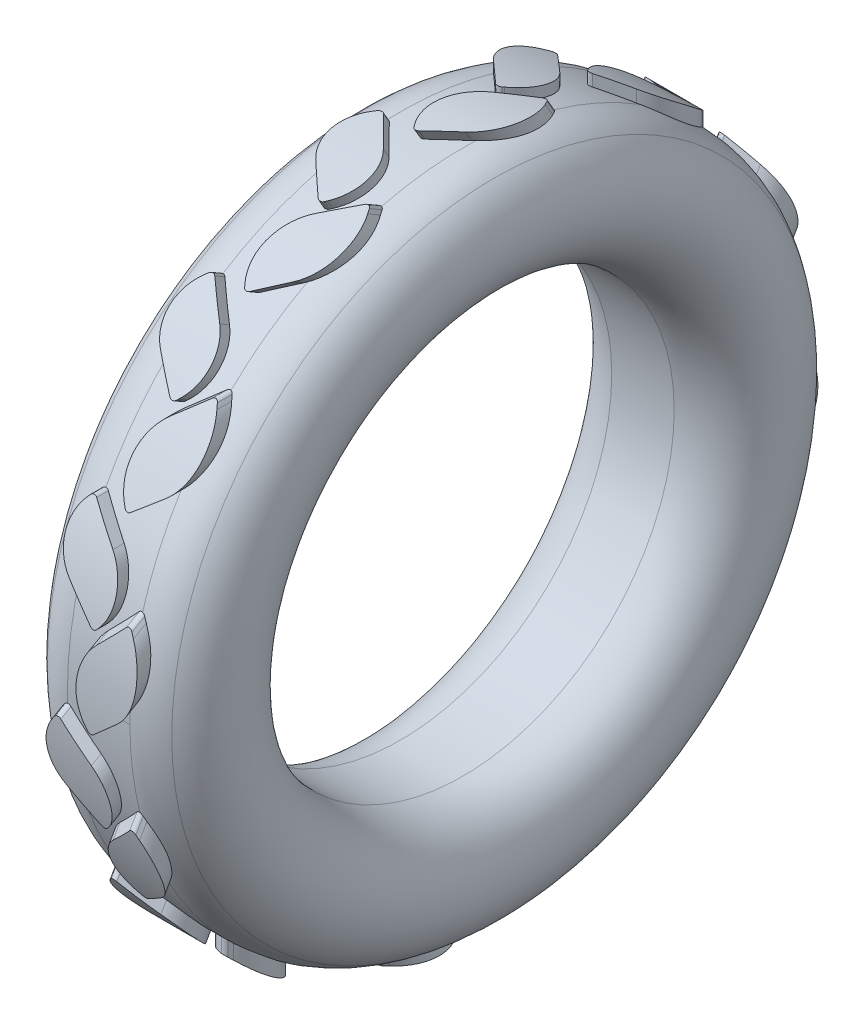
from build123d import *

# Parameters (mm, degrees)
BOSS_EXTRUDE2_REACH = 183.851
CUT_EXTRUDE1_DEPTH  = 117.403984849
CIRPATTERN2_COUNT   = 12


with BuildPart() as part:
    # Sketch1 → Revolve2 (revolve)
    with BuildSketch(Plane.XY, mode=Mode.PRIVATE) as revolve2_sk:
        with BuildLine():
            Line((-7.5, 80), (7.5, 80))
            ThreePointArc((7.5, 80), (11.445221398, 79.332926724), (14.951817501, 77.405871354))
            ThreePointArc((14.951817501, 77.405871354), (20.08259217, 61.607964749), (7.5, 50.764668382))
            Line((7.5, 50.764668382), (-7.5, 50.764668382))
            ThreePointArc((-7.5, 50.764668382), (-20.08259217, 61.607964749), (-14.951817501, 77.405871354))
            ThreePointArc((-14.951817501, 77.405871354), (-11.445221398, 79.332926724), (-7.5, 80))
        make_face()
    revolve(revolve2_sk.sketch.rotate(Axis((0, 0, 0), (1, 0, 0)), 90), axis=Axis((0, 0, 0), (1, 0, 0)))

    # Sketch3 → Boss-Extrude2 (add, up to next)
    with BuildSketch(Plane(origin=(0, 82, 0), x_dir=(1, 0, 0), z_dir=(0, 1, 0)), mode=Mode.PRIVATE) as boss_extrude2_sk1:
        with BuildLine():
            Line((-1.101256595, 16.463545507), (-7.765089072, 22.606945227))
            ThreePointArc((-7.765089072, 22.606945227), (-10.973435179, 29.439481126), (-8.491780794, 36.568185291))
            Line((-8.491780794, 36.568185291), (-8.176119623, 36.926638579))
            ThreePointArc((-8.176119623, 36.926638579), (-7.477617242, 37.264396564), (-6.747823451, 37.000982334))
            Line((-6.747823451, 37.000982334), (-0.083990974, 30.857582614))
            ThreePointArc((-0.083990974, 30.857582614), (3.124355134, 24.025046715), (0.642700748, 16.89634255))
            Line((0.642700748, 16.89634255), (0.327039578, 16.537889262))
            ThreePointArc((0.327039578, 16.537889262), (-0.371462804, 16.200131277), (-1.101256595, 16.463545507))
        make_face()
    boss_extrude2_tool1 = extrude(boss_extrude2_sk1.sketch, amount=-BOSS_EXTRUDE2_REACH, mode=Mode.PRIVATE) - part.part
    # Sketch3 → Boss-Extrude2 (add, up to next)
    with BuildSketch(Plane(origin=(0, 82, 0), x_dir=(1, 0, 0), z_dir=(0, 1, 0)), mode=Mode.PRIVATE) as boss_extrude2_sk2:
        with BuildLine():
            Line((1.084752357, 37.609371056), (6.991157215, 42.191838317))
            ThreePointArc((6.991157215, 42.191838317), (10.787185022, 48.877835615), (8.715761537, 56.281996049))
            Line((8.715761537, 56.281996049), (8.11427934, 57.045310452))
            ThreePointArc((8.11427934, 57.045310452), (7.450320314, 57.418978065), (6.715839438, 57.216476421))
            Line((6.715839438, 57.216476421), (0.80943458, 52.63400916))
            ThreePointArc((0.80943458, 52.63400916), (-2.986593227, 45.948011861), (-0.915169742, 38.543851427))
            Line((-0.915169742, 38.543851427), (-0.313687545, 37.780537025))
            ThreePointArc((-0.313687545, 37.780537025), (0.350271481, 37.406869411), (1.084752357, 37.609371056))
        make_face()
    boss_extrude2_tool2 = extrude(boss_extrude2_sk2.sketch, amount=-BOSS_EXTRUDE2_REACH, mode=Mode.PRIVATE) - part.part
    boss_extrude2_1 = boss_extrude2_tool1.solids().sort_by_distance((-3.92454, 82, -26.732264))[0]
    add(boss_extrude2_1)
    boss_extrude2_2 = boss_extrude2_tool2.solids().sort_by_distance((3.900296, 82, -47.412924))[0]
    add(boss_extrude2_2)
    boss_extrude2 = boss_extrude2_1 + boss_extrude2_2  # Boss-Extrude2 as one shape, for the pattern or mirror that repeats it

    # Sketch4 → Cut-Extrude1 (cut, symmetric)
    with BuildSketch(Plane(origin=(0, 0, 0), x_dir=(0, 0, -1), z_dir=(1, 0, 0))):
        with BuildLine():
            Line((16.198779388, 82), (16.198779388, 80.894063728))
            ThreePointArc((16.198779388, 80.894063728), (38.372838025, 73.032700223), (57.42638555, 59.232256775))
            Line((57.42638555, 59.232256775), (57.42638555, 82))
            add(Edge.make_bspline(
                [(16.198779388, 82), (15.488555572, 83.729394535), (19.769359109, 84.523606768), (32.707694781, 86.891237657), (47.667286982, 94.196998332), (57.42638555, 82)],
                knots=[0, 0, 0, 0, 0.106935157, 0.195115191, 1, 1, 1, 1], degree=3))
        make_face()
    cut_extrude1 = extrude(amount=CUT_EXTRUDE1_DEPTH, both=True, mode=Mode.SUBTRACT)

    # CirPattern2: Boss-Extrude2, Cut-Extrude1 ×12 about axis
    cirpattern2_axis = Axis((0, 0, 0), (1, 0, 0))
    add([boss_extrude2.rotate(cirpattern2_axis, i * 360 / CIRPATTERN2_COUNT) for i in range(1, CIRPATTERN2_COUNT)])
    add([cut_extrude1.rotate(cirpattern2_axis, i * 360 / CIRPATTERN2_COUNT) for i in range(1, CIRPATTERN2_COUNT)], mode=Mode.SUBTRACT)


solid = part.part
